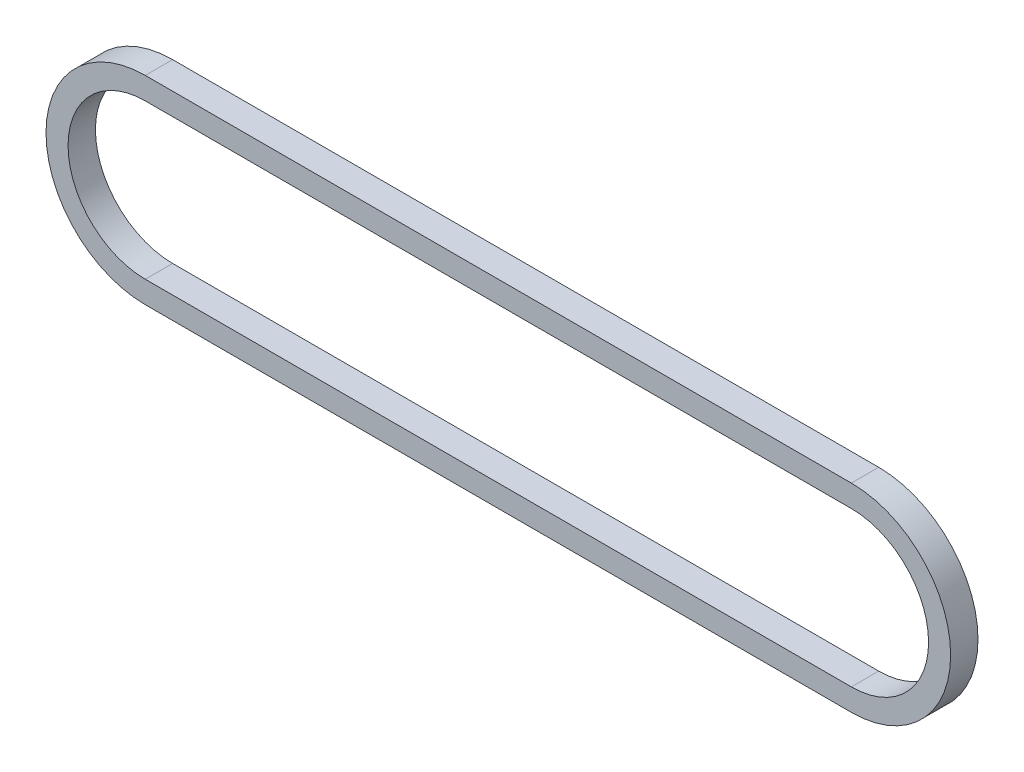
from build123d import *

# Parameters (mm, degrees)
BOSS_EXTRUDE1_DEPTH = 7.874


with BuildPart() as part:
    # Sketch1 → Boss-Extrude1 (new body)
    with BuildSketch(Plane.XY):
        with BuildLine():
            Line((0, 28.575), (203.2, 28.575))
            ThreePointArc((203.2, 28.575), (231.775, 0), (203.2, -28.575))
            Line((203.2, -28.575), (0, -28.575))
            ThreePointArc((0, -28.575), (-28.575, 0), (0, 28.575))
        make_face()
        with BuildLine():
            Line((0, 22.225), (203.2, 22.225))
            ThreePointArc((203.2, 22.225), (225.425, 0), (203.2, -22.225))
            Line((203.2, -22.225), (0, -22.225))
            ThreePointArc((0, -22.225), (-22.225, 0), (0, 22.225))
        make_face(mode=Mode.SUBTRACT)
    extrude(amount=BOSS_EXTRUDE1_DEPTH)


solid = part.part
